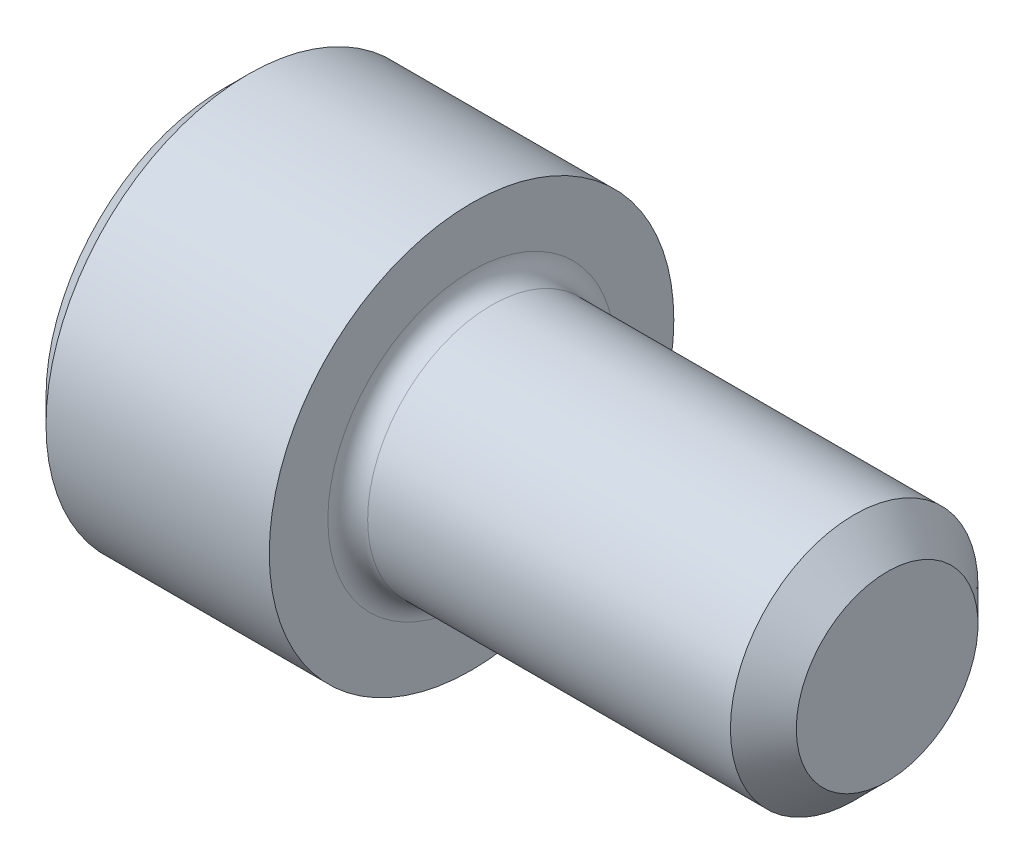
from build123d import *

# Parameters (mm, degrees)
FILLET1_R   = 0.2286
HEX_2_DEPTH = 1.2954


with BuildPart() as part:
    # BodySke → Base-Revolve (revolve)
    with BuildSketch(Plane.XY):
        Polygon((0, 0), (0, 2.0447), (0.2794, 2.3241), (2.8448, 2.3241), (2.8448, 1.4224), (7.24154, 1.4224), (7.62, 1.04394), (7.62, 0), align=None)
    revolve(axis=Axis((-31.75, 0, 0), (1, 0, 0)))

    # Fillet1
    fillet1_edges = [part.edges().sort_by_distance(p)[0] for p in [
        (2.8448, -1.4224, 0),
    ]]
    fillet(fillet1_edges, radius=FILLET1_R)

    # Sketch2 → Hex-PreBroach (revolve, cut)
    with BuildSketch(Plane.XY):
        Polygon((0, 1.1938), (1.2954, 1.1938), (1.984640751, 0), (0, 0), align=None)
    revolve(axis=Axis((0, 0, 0), (1, 0, 0)), mode=Mode.SUBTRACT)

    # Sketch3 → Hex 2 (cut)
    with BuildSketch(Plane(origin=(0, 0, 0), x_dir=(0, 0.5, 0.866025404), z_dir=(-1, 0, 0))):
        Polygon((0.689240751, 1.1938), (-0.689240751, 1.1938), (-1.378481503, 0), (-0.689240751, -1.1938), (0.689240751, -1.1938), (1.378481503, 0), align=None)
    extrude(amount=-HEX_2_DEPTH, mode=Mode.SUBTRACT)


solid = part.part
